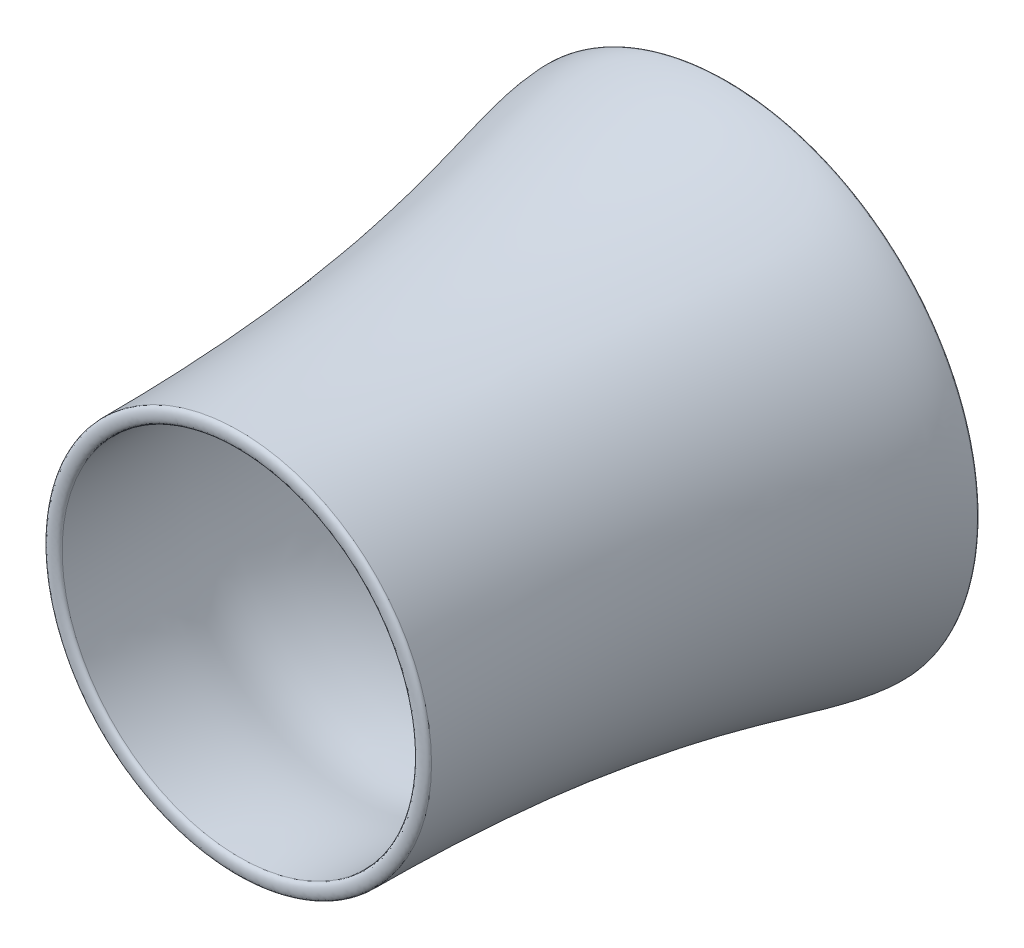
from build123d import *


with BuildPart() as part:
    # Sketch21 → Revolve2 (revolve)
    with BuildSketch(Plane(origin=(0, 0, 0), x_dir=(1, 0, 0), z_dir=(0, 1, 0))):
        with BuildLine():
            Line((-415.046918134, -1171.929995514), (-450.143329298, -1171.929995514))
            add(Edge.make_bspline(
                [(-589.099391581, -32.243936504), (-589.099391581, -157.62788888), (-450.143329298, -441.620875129), (-450.143329298, -1171.929995514)],
                knots=[0, 0, 0, 0, 1, 1, 1, 1], degree=3))
            Line((-589.099391581, -32.243936504), (-422.199759508, -32.243936504))
            add(Edge.make_bspline(
                [(-422.199759508, -32.243936504), (-422.199759508, -84.879689026), (-496.283010683, -391.324653201), (-428.719828511, -617.113742102), (-443.486134022, -959.839083612), (-415.046918134, -882.821374874), (-415.046918134, -1171.929995514)],
                knots=[0, 0, 0, 0, 0.158009172, 0.206506907, 0.484977351, 1, 1, 1, 1], degree=3))
        make_face()
    revolve(axis=Axis((0, 0, 99.684784321), (0, 0, -1)))


with BuildPart() as body_2:
    # Sketch22 → Revolve3 (revolve)
    with BuildSketch(Plane(origin=(0, 0, 0), x_dir=(1, 0, 0), z_dir=(0, 1, 0))):
        with BuildLine():
            Line((-589.099391581, -32.243936504), (-422.199759508, -32.243936504))
            add(Edge.make_bspline(
                [(-589.099391581, -32.243936504), (-589.099391581, -15.310603171), (-422.199759508, -15.310603171), (-422.199759508, -32.243936504)],
                knots=[0, 0, 0, 0, 1, 1, 1, 1], degree=3))
        make_face()
    revolve(axis=Axis((0, 0, 99.684784321), (0, 0, -1)))


with BuildPart() as body_3:
    # Sketch23 → Revolve4 (revolve)
    with BuildSketch(Plane(origin=(0, 0, 0), x_dir=(1, 0, 0), z_dir=(0, 1, 0))):
        with BuildLine():
            Line((-450.143329298, -1171.929995514), (-415.046918134, -1171.929995514))
            add(Edge.make_bspline(
                [(-450.143329298, -1171.929995514), (-450.143329298, -1184.629995514), (-415.046918134, -1184.629995514), (-415.046918134, -1171.929995514)],
                knots=[0, 0, 0, 0, 1, 1, 1, 1], degree=3))
        make_face()
    revolve(axis=Axis((0, 0, 1104.756830123), (0, 0, -1)))


solid = Compound([part.part, body_2.part, body_3.part])
